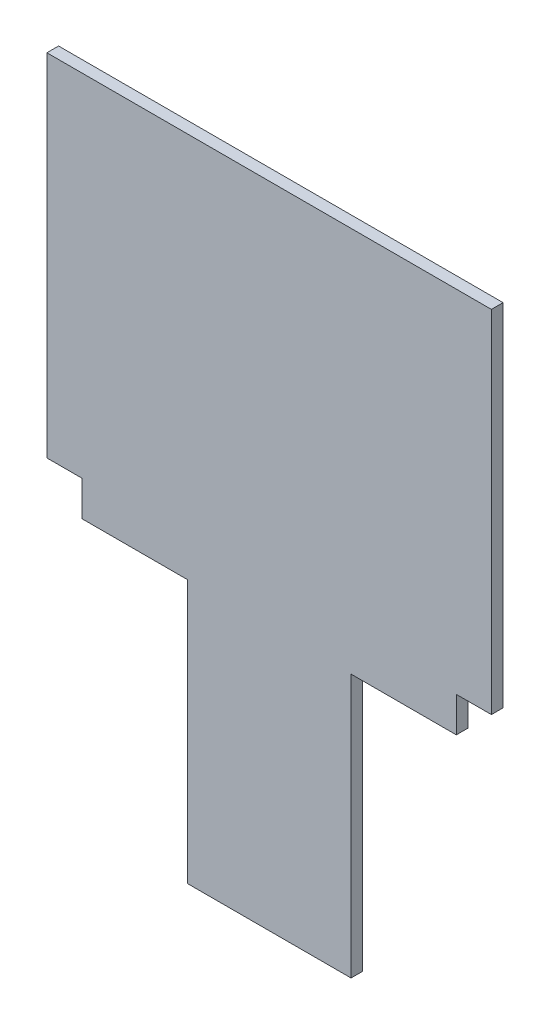
from build123d import *

# Parameters (mm, degrees)
AUFSATZ_LINEAR_AUSTRAGEN1_DEPTH = 2


with BuildPart() as part:
    # Skizze1 → Aufsatz-Linear austragen1 (new body)
    with BuildSketch(Plane.XY):
        Polygon((14, -113), (14, -68), (32, -68), (32, -62), (38, -62), (38, -2), (-38, -2), (-38, -62), (-32, -62), (-32, -68), (-14, -68), (-14, -113), align=None)
    extrude(amount=-AUFSATZ_LINEAR_AUSTRAGEN1_DEPTH)


solid = part.part
